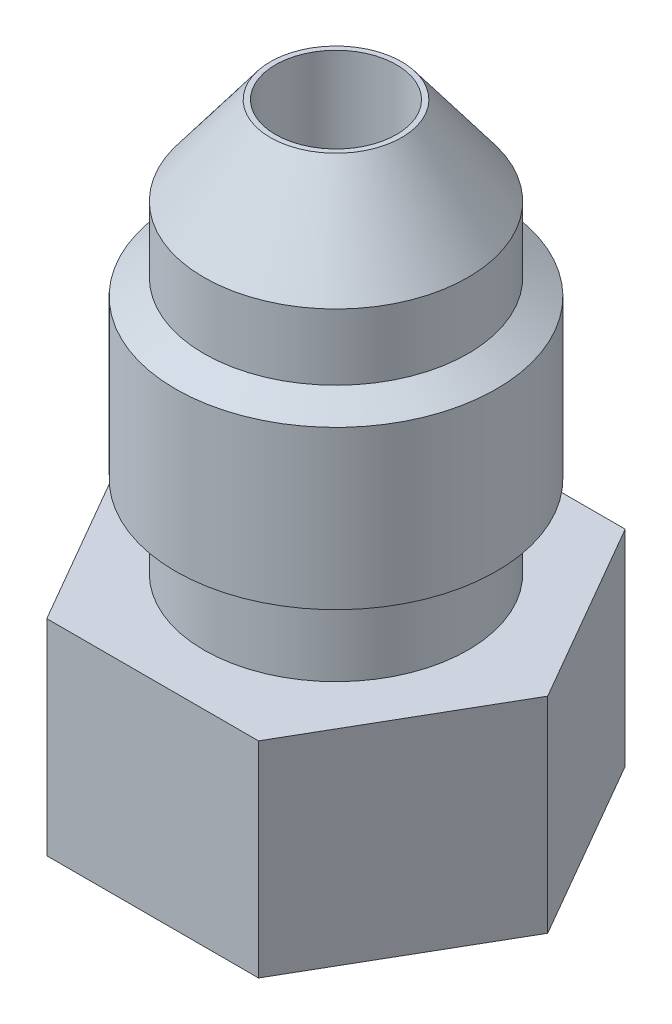
from build123d import *

# Parameters (mm, degrees)
BOSS_EXTRUDE1_DEPTH = 7.112
SKETCH2_R           = 4.572
BOSS_EXTRUDE2_DEPTH = 11.176
SKETCH4_R           = 4.0005
CUT_EXTRUDE1_DEPTH  = 4.7625
SKETCH5_R           = 2.0955
CUT_EXTRUDE2_DEPTH  = 22.336


with BuildPart() as part:
    # Sketch1 → Boss-Extrude1 (new body)
    with BuildSketch(Plane(origin=(0, 0, 0), x_dir=(1, 0, 0), z_dir=(0, 1, 0))):
        Polygon((7.332348419, 0), (3.666174209, 6.35), (-3.666174209, 6.35), (-7.332348419, 0), (-3.666174209, -6.35), (3.666174209, -6.35), align=None)
    extrude(amount=BOSS_EXTRUDE1_DEPTH)

    # Sketch2 → Boss-Extrude2 (add)
    with BuildSketch(Plane(origin=(0, 7.112, 0), x_dir=(1, 0, 0), z_dir=(0, 1, 0))):
        Circle(SKETCH2_R)
    extrude(amount=BOSS_EXTRUDE2_DEPTH)

    # Sketch3 → Revolve1 (revolve)
    with BuildSketch(Plane.XY):
        Polygon((0, 18.288), (-4.572, 18.288), (-2.275167255, 21.336), (0, 21.336), align=None)
    revolve(axis=Axis((0, 24.854353551, 0), (0, -1, 0)))

    # Sketch4 → Cut-Extrude1 (cut)
    with BuildSketch(Plane.XZ):
        Circle(SKETCH4_R)
    extrude(amount=-CUT_EXTRUDE1_DEPTH, mode=Mode.SUBTRACT)

    # Sketch5 → Cut-Extrude2 (cut, through all)
    with BuildSketch(Plane(origin=(0, 21.336, 0), x_dir=(1, 0, 0), z_dir=(0, 1, 0))):
        Circle(SKETCH5_R)
    extrude(amount=-CUT_EXTRUDE2_DEPTH, mode=Mode.SUBTRACT)

    # Sketch7 → Revolve2 (revolve)
    with BuildSketch(Plane.XY):
        Polygon((-4.572, 9.398), (-5.55625, 9.966257002), (-5.55625, 15.433742998), (-4.572, 16.002), align=None)
    revolve(axis=Axis((0, 22.381556864, 0), (0, -1, 0)))


solid = part.part
